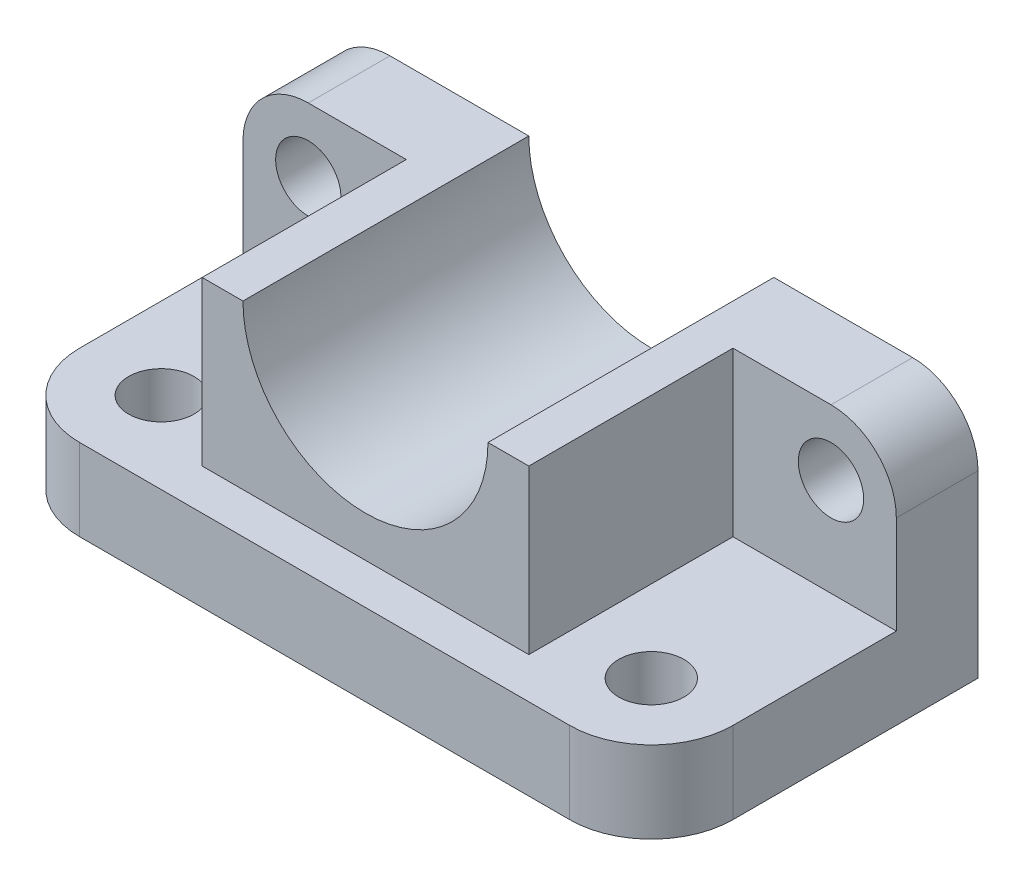
from build123d import *

# Parameters (mm, degrees)
BOSS_EXTRUDE1_DEPTH = 10
BOSS_EXTRUDE2_DEPTH = 30
CUT_EXTRUDE1_REACH  = 63.033
CUT_EXTRUDE2_REACH  = 62
SKETCH3_R           = 4
FILLET1_R           = 10
FILLET2_R           = 8
CUT_EXTRUDE3_REACH  = 60.31
SKETCH4_R           = 4


with BuildPart() as part:
    # Sketch1 → Boss-Extrude1 (new body)
    with BuildSketch(Plane(origin=(0, 0, 0), x_dir=(1, 0, 0), z_dir=(0, 1, 0))):
        Polygon((40, 0), (40, 30), (20, 30), (20, 5), (0, 5), (0, 0), align=None)
    extrude(amount=BOSS_EXTRUDE1_DEPTH)

    # Sketch1_3 → Boss-Extrude2 (add)
    with BuildSketch(Plane(origin=(0, 0, 0), x_dir=(1, 0, 0), z_dir=(0, 1, 0))):
        Polygon((20, 30), (40, 30), (40, 40), (0, 40), (0, 5), (20, 5), align=None)
    extrude(amount=BOSS_EXTRUDE2_DEPTH)

    # Sketch2 → Cut-Extrude1 (cut, up to next)
    with BuildSketch(Plane.XY.offset(-5), mode=Mode.PRIVATE) as cut_extrude1_sk1:
        with BuildLine():
            Line((15, 30), (0, 30))
            Line((0, 30), (0, 15))
            ThreePointArc((0, 15), (10.606601718, 19.393398282), (15, 30))
        make_face()
    cut_extrude1_tool1 = extrude(cut_extrude1_sk1.sketch, amount=-CUT_EXTRUDE1_REACH, mode=Mode.PRIVATE) & part.part
    add(cut_extrude1_tool1.solids().sort_by_distance((6.366198, 23.633802, -5))[0], mode=Mode.SUBTRACT)

    # Sketch3 → Cut-Extrude2 (cut, up to next)
    with BuildSketch(Plane(origin=(0, 10, 0), x_dir=(1, 0, 0), z_dir=(0, 1, 0)), mode=Mode.PRIVATE) as cut_extrude2_sk1:
        with Locations((30, 10)):
            Circle(SKETCH3_R)
    cut_extrude2_tool1 = extrude(cut_extrude2_sk1.sketch, amount=-CUT_EXTRUDE2_REACH, mode=Mode.PRIVATE) & part.part
    add(cut_extrude2_tool1.solids().sort_by_distance((30, 10, -10))[0], mode=Mode.SUBTRACT)

    # Fillet1
    fillet1_edges = [part.edges().sort_by_distance(p)[0] for p in [
        (40, 5, 0),
    ]]
    fillet(fillet1_edges, radius=FILLET1_R)

    # Fillet2
    fillet2_edges = [part.edges().sort_by_distance(p)[0] for p in [
        (40, 30, -35),
    ]]
    fillet(fillet2_edges, radius=FILLET2_R)

    # Sketch4 → Cut-Extrude3 (cut, up to next)
    with BuildSketch(Plane.XY.offset(-30), mode=Mode.PRIVATE) as cut_extrude3_sk1:
        with Locations((32, 22)):
            Circle(SKETCH4_R)
    cut_extrude3_tool1 = extrude(cut_extrude3_sk1.sketch, amount=-CUT_EXTRUDE3_REACH, mode=Mode.PRIVATE) & part.part
    add(cut_extrude3_tool1.solids().sort_by_distance((32, 22, -30))[0], mode=Mode.SUBTRACT)

    # Mirror1: part across plane


with BuildPart() as part_1:
    add(part.part)
    add(part.part.mirror(Plane(origin=(0, 10, 0), x_dir=(0, 0, 1), z_dir=(-1, 0, 0))))


solid = part_1.part
